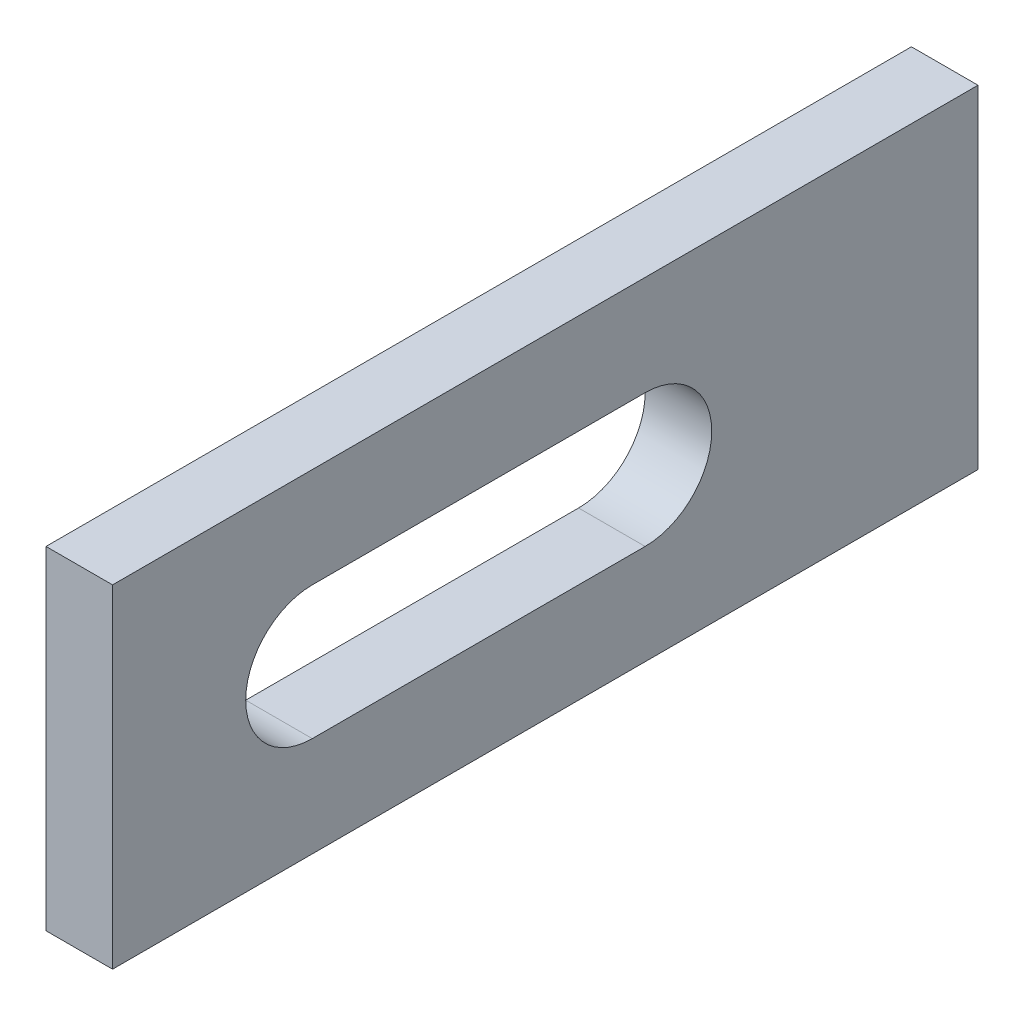
from build123d import *

# Parameters (mm, degrees)
ESQUISSE1_W             = 10
ESQUISSE1_H             = 50
BOSS_EXTRU_1_DEPTH      = 65
ENL_V_MAT_EXTRU_1_DEPTH = 110


with BuildPart() as part:
    # Esquisse1 → Boss.-Extru.1 (new body, symmetric)
    with BuildSketch(Plane.XY):
        Rectangle(ESQUISSE1_W, ESQUISSE1_H)
    extrude(amount=BOSS_EXTRU_1_DEPTH, both=True)

    # Esquisse2 → Enlèv. mat.-Extru.1 (cut)
    with BuildSketch(Plane(origin=(5, 0, 0), x_dir=(0, 0, -1), z_dir=(1, 0, 0))):
        with BuildLine():
            Line((-35, 10), (15, 10))
            ThreePointArc((15, 10), (25, 0), (15, -10))
            Line((15, -10), (-35, -10))
            ThreePointArc((-35, -10), (-45, 0), (-35, 10))
        make_face()
    extrude(amount=-ENL_V_MAT_EXTRU_1_DEPTH, mode=Mode.SUBTRACT)


solid = part.part
